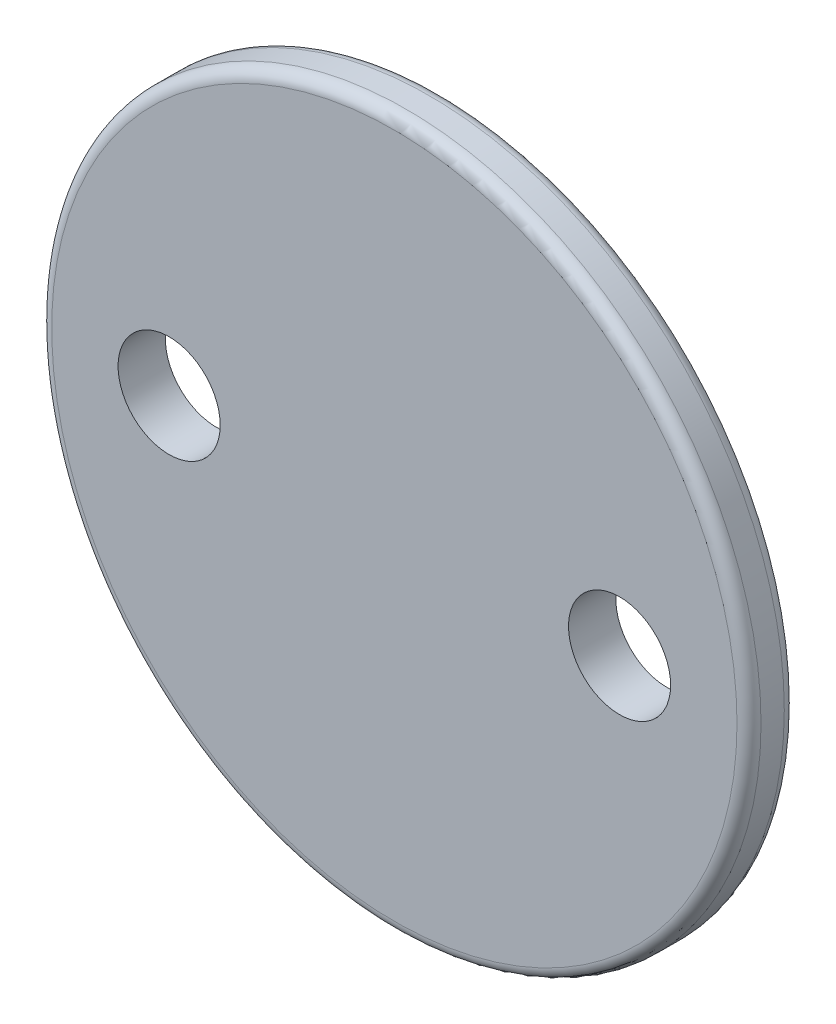
from build123d import *

# Parameters (mm, degrees)
SKETCH1_R               = 4.5
SKETCH1_R_2             = 2.5
BOSS_EXTRUDE1_DEPTH     = 2.5
SKETCH2_R               = 15
BOSS_EXTRUDE2_DEPTH     = 2
SKETCH3_R               = 2.159
CUT_EXTRUDE1_DEPTH      = 1
CUT_EXTRUDE1_DEPTH_BACK = 5.5
FILLET2_R               = 0.508


with BuildPart() as part:
    # Sketch1 → Boss-Extrude1 (new body)
    with BuildSketch(Plane.XY):
        Circle(SKETCH1_R)
        Circle(SKETCH1_R_2, mode=Mode.SUBTRACT)
    extrude(amount=BOSS_EXTRUDE1_DEPTH)

    # Sketch2 → Boss-Extrude2 (add)
    with BuildSketch(Plane.XY.offset(2.5)):
        Circle(SKETCH2_R)
    extrude(amount=BOSS_EXTRUDE2_DEPTH)

    # Sketch3 → Cut-Extrude1 (cut, two sides)
    with BuildSketch(Plane.XY.offset(4.5)) as cut_extrude1_sk:
        with Locations((-9.525, 0)):
            Circle(SKETCH3_R)
        with Locations((9.525, 0)):
            Circle(SKETCH3_R)
    extrude(amount=CUT_EXTRUDE1_DEPTH, mode=Mode.SUBTRACT)
    extrude(cut_extrude1_sk.sketch, amount=-CUT_EXTRUDE1_DEPTH_BACK, mode=Mode.SUBTRACT)

    # Fillet2
    fillet2_edges = [part.edges().sort_by_distance(p)[0] for p in [
        (-15, 0, 4.5),
        (-15, 0, 2.5),
    ]]
    fillet(fillet2_edges, radius=FILLET2_R)


solid = part.part
